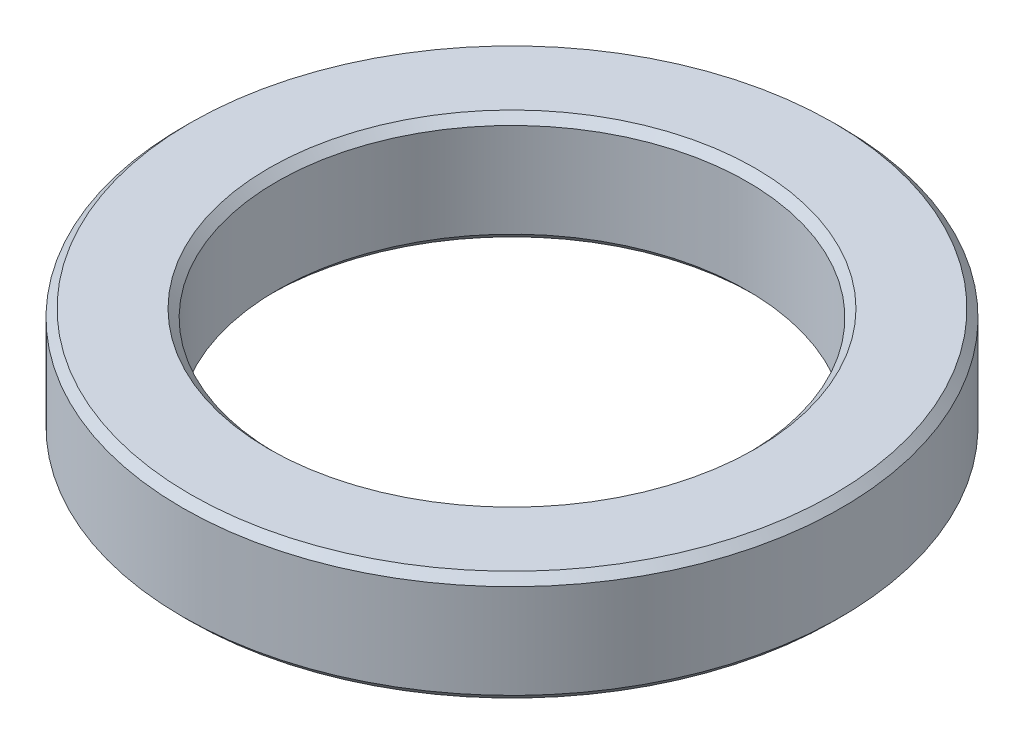
from build123d import *

# Parameters (mm, degrees)
SKETCH_1_R      = 21
SKETCH_1_R_2    = 15
EXTRUDE_1_DEPTH = 7
CHAMFER_1_SIZE  = 0.5


with BuildPart() as part:
    # 草图1 → 凸台-拉伸1 (new body)
    with BuildSketch(Plane(origin=(0, 0, 0), x_dir=(1, 0, 0), z_dir=(0, 1, 0))):
        Circle(SKETCH_1_R)
        Circle(SKETCH_1_R_2, mode=Mode.SUBTRACT)
    extrude(amount=EXTRUDE_1_DEPTH)

    # 倒角1
    chamfer_1_edges = [part.edges().sort_by_distance(p)[0] for p in [
        (-21, 0, 0),
        (-21, 7, 0),
        (-15, 0, 0),
        (-15, 7, 0),
    ]]
    chamfer(chamfer_1_edges, length=CHAMFER_1_SIZE)


solid = part.part
